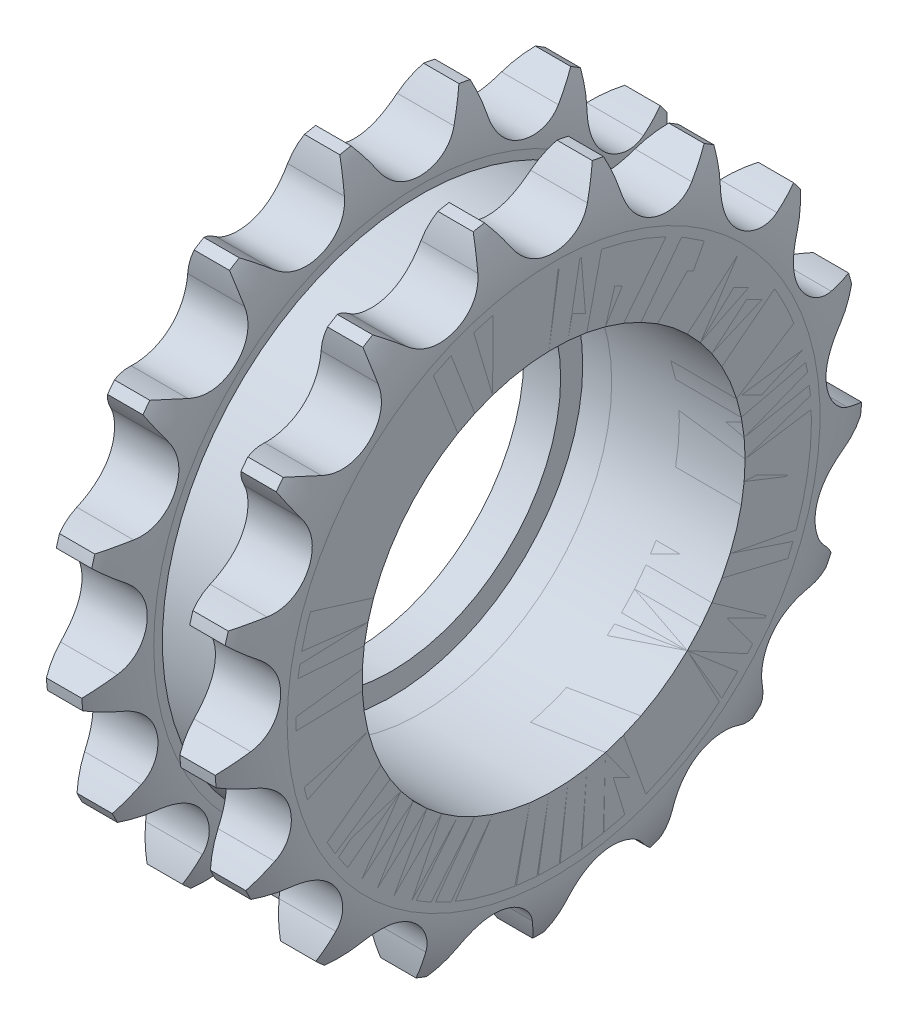
from build123d import *

# Parameters (mm, degrees)
EXTRUDE_1_DEPTH          = 8.93
PATTERN_CIRCULAR_1_COUNT = 17
SKETCH_4_R               = 35
EXTRUDE_3_DEPTH          = 18.11
PATTERN_LINEAR_1_COUNT   = 2
PATTERN_LINEAR_1_PITCH   = 18.11
SKETCH_5_R               = 26
CUT_EXTRUDE_1_DEPTH      = 22.04
SKETCH_6_R               = 23
CUT_EXTRUDE_2_DEPTH      = 5


with BuildPart() as part:
    # 草图1 → 凸台-拉伸1 (new body)
    with BuildSketch(Plane(origin=(0, 0, 0), x_dir=(0, 0, -1), z_dir=(1, 0, 0))):
        with BuildLine():
            Line((0, 37.19745), (0, 0))
            Line((0, 0), (13.437268816, 34.68558913))
            ThreePointArc((13.437268816, 34.68558913), (10.930235366, 36.518879671), (9.675725981, 39.360072577))
            ThreePointArc((9.675725981, 39.360072577), (9.321318967, 41.243942554), (8.847322826, 43.10133268))
            ThreePointArc((8.847322826, 43.10133268), (8.084978784, 43.250816386), (7.320114393, 43.386817414))
            ThreePointArc((7.320114393, 43.386817414), (6.20715945, 41.826079858), (5.196152423, 40.19745))
            ThreePointArc((5.196152423, 40.19745), (3, 38.001297577), (0, 37.19745))
        make_face()
    extrude_1 = extrude(amount=EXTRUDE_1_DEPTH)

    # 阵列(圆周)1: 凸台-拉伸1 ×17 about axis
    pattern_circular_1_axis = Axis((0, 0, 0), (1, 0, 0))
    for i in range(1, PATTERN_CIRCULAR_1_COUNT):
        add(extrude_1.rotate(pattern_circular_1_axis, i * 360 / PATTERN_CIRCULAR_1_COUNT))

    # 草图2 → 切除-旋转1 (revolve, cut)
    with BuildSketch(Plane.XY):
        with BuildLine():
            Line((2.06375, 44), (6.86625, 44))
            ThreePointArc((6.86625, 44), (8.405394437, 40.220150661), (8.93, 36.172803922))
            Line((8.93, 36.172803922), (8.93, 48.352782986))
            Line((8.93, 48.352782986), (0, 48.352782986))
            Line((0, 48.352782986), (0, 36.172803922))
            ThreePointArc((0, 36.172803922), (0.524605563, 40.220150661), (2.06375, 44))
        make_face()
    revolve(axis=Axis((0, 0, 0), (1, 0, 0)), mode=Mode.SUBTRACT)


with BuildPart() as body_2:
    # 草图4 → 凸台-拉伸3 (new body)
    with BuildSketch(Plane(origin=(8.93, 0, 0), x_dir=(0, 0, -1), z_dir=(1, 0, 0))):
        Circle(SKETCH_4_R)
    extrude(amount=EXTRUDE_3_DEPTH)


with BuildPart() as pattern_linear_1_1:
    # 阵列(线性)1: pattern copy
    add(part.part.moved(Location(Vector(1, 0, 0) * (1 * PATTERN_LINEAR_1_PITCH))))


with BuildPart() as cut_extrude_1_tool:
    # 草图5 → 切除-拉伸1 (new body)
    with BuildSketch(Plane(origin=(27.04, 0, 0), x_dir=(0, 0, -1), z_dir=(1, 0, 0))):
        Circle(SKETCH_5_R)
    extrude(amount=-CUT_EXTRUDE_1_DEPTH)


with BuildPart() as part_1:
    add(part.part)

    # 切除-拉伸1: cut by cut_extrude_1_tool
    add(cut_extrude_1_tool.part, mode=Mode.SUBTRACT)

    # 草图6 → 切除-拉伸2 (cut)
    with BuildSketch(Plane(origin=(5, 0, 0), x_dir=(0, 0, -1), z_dir=(1, 0, 0))):
        Circle(SKETCH_6_R)
    extrude(amount=-CUT_EXTRUDE_2_DEPTH, mode=Mode.SUBTRACT)


with BuildPart() as body_2_1:
    add(body_2.part)

    # 切除-拉伸1: cut by cut_extrude_1_tool
    add(cut_extrude_1_tool.part, mode=Mode.SUBTRACT)


with BuildPart() as pattern_linear_1_1_1:
    add(pattern_linear_1_1.part)

    # 切除-拉伸1: cut by cut_extrude_1_tool
    add(cut_extrude_1_tool.part, mode=Mode.SUBTRACT)


solid = Compound([part_1.part, body_2_1.part, pattern_linear_1_1_1.part])
